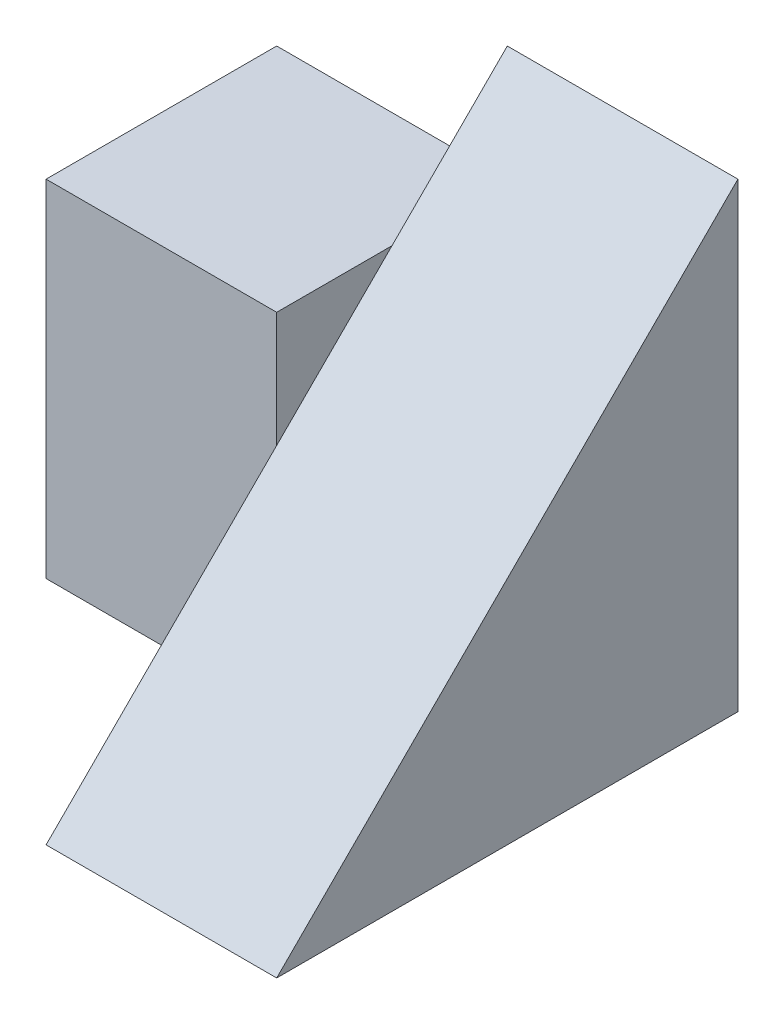
from build123d import *

# Parameters (mm, degrees)
SKETCH1_W           = 4
SKETCH1_H           = 4
BOSS_EXTRUDE1_DEPTH = 2
SKETCH2_W           = 2
SKETCH2_H           = 3
BOSS_EXTRUDE2_DEPTH = 2
CUT_EXTRUDE1_DEPTH  = 2
CUT_EXTRUDE2_DEPTH  = 2


with BuildPart() as part:
    # Sketch1 → Boss-Extrude1 (new body)
    with BuildSketch(Plane(origin=(0, 0, 0), x_dir=(0, 0, -1), z_dir=(1, 0, 0))):
        with Locations((2, 2)):
            Rectangle(SKETCH1_W, SKETCH1_H)
    extrude(amount=BOSS_EXTRUDE1_DEPTH)

    # Sketch2 → Boss-Extrude2 (add)
    with BuildSketch(Plane.ZY):
        with Locations((-3, 1.5)):
            Rectangle(SKETCH2_W, SKETCH2_H)
    extrude(amount=BOSS_EXTRUDE2_DEPTH)

    # Sketch3 → Cut-Extrude1 (cut)
    with BuildSketch(Plane.ZY.offset(2)):
        Polygon((-2, 0), (-4, 3), (-4, 0), align=None)
    extrude(amount=-CUT_EXTRUDE1_DEPTH, mode=Mode.SUBTRACT)

    # Sketch4 → Cut-Extrude2 (cut)
    with BuildSketch(Plane(origin=(2, 0, 0), x_dir=(0, 0, -1), z_dir=(1, 0, 0))):
        Polygon((4, 4), (0, 0), (0, 4), align=None)
    extrude(amount=-CUT_EXTRUDE2_DEPTH, mode=Mode.SUBTRACT)


solid = part.part
